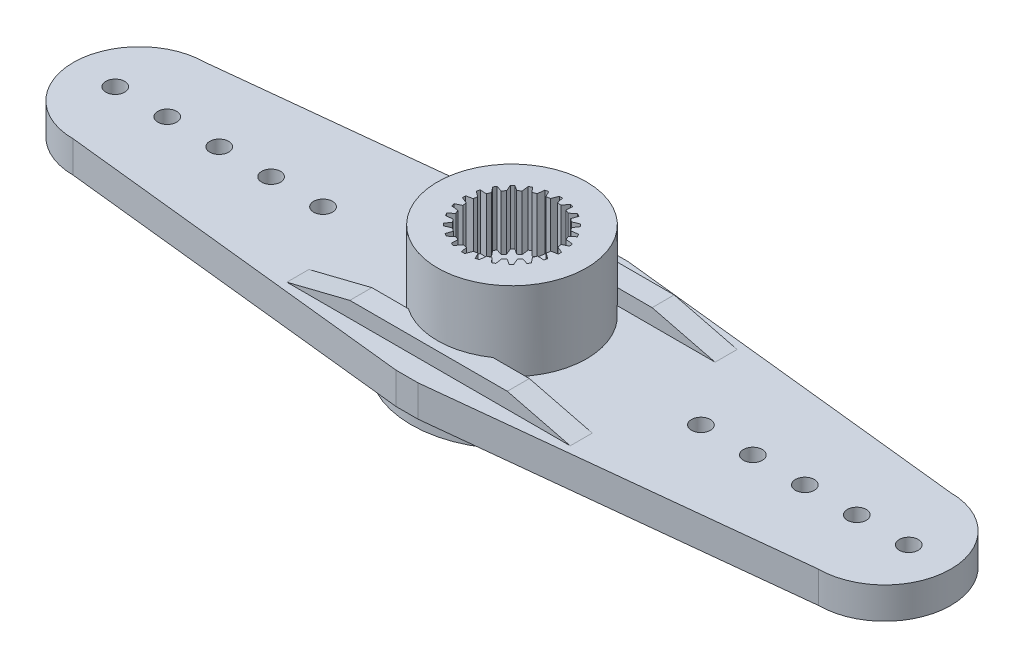
from build123d import *

# Parameters (mm, degrees)
IZIM1_R                     = 6.4
IZIM1_R_2                   = 4.735
Y_KSEKLIK_EKSTR_ZYON1_DEPTH = 2.8
IZIM3_R                     = 4.735
Y_KSEKLIK_EKSTR_ZYON3_DEPTH = 7.8
IZIM6_R                     = 0.6
Y_KSEKLIK_EKSTR_ZYON5_DEPTH = 2
Y_KSEKLIK_EKSTR_ZYON6_DEPTH = 0.8
KES_EKSTR_ZYON1_DEPTH       = 2
KES_EKSTR_ZYON2_DEPTH       = 2
KES_EKSTR_ZYON3_DEPTH       = 2
KES_EKSTR_ZYON4_DEPTH       = 2
KES_EKSTR_ZYON5_DEPTH       = 2
KES_EKSTR_ZYON6_DEPTH       = 2
IZIM16_R                    = 3.1
KES_EKSTR_ZYON8_DEPTH       = 3
IZIM18_W                    = 18
IZIM18_H                    = 1.4
Y_KSEKLIK_EKSTR_ZYON7_DEPTH = 1
KES_EKSTR_ZYON11_DEPTH      = 12
IZIM20_R                    = 2.68
KES_EKSTR_ZYON13_DEPTH      = 3.5
IZIM21_R                    = 1.65
KES_EKSTR_ZYON14_DEPTH      = 3.5
KES_EKSTR_ZYON16_DEPTH      = 12.5
DAIRESEL_KAPLAMA1_COUNT     = 24


with BuildPart() as part:
    # Çizim1 → Yükseklik-Ekstrüzyon1 (new body)
    with BuildSketch(Plane(origin=(0, 0, 0), x_dir=(1, 0, 0), z_dir=(0, 1, 0))):
        with Locations(Location((0, 0, 0), (0, 0, 270))):
            Circle(IZIM1_R)
        with Locations(Location((0, 0, 0), (0, 0, 270))):
            Circle(IZIM1_R_2, mode=Mode.SUBTRACT)
    extrude(amount=Y_KSEKLIK_EKSTR_ZYON1_DEPTH)

    # Çizim3 → Yükseklik-Ekstrüzyon3 (add)
    with BuildSketch(Plane.XZ):
        with Locations(Location((0, 0, 0), (0, 0, 270))):
            Circle(IZIM3_R)
    extrude(amount=-Y_KSEKLIK_EKSTR_ZYON3_DEPTH)

    # Çizim6 → Yükseklik-Ekstrüzyon5 (add)
    with BuildSketch(Plane(origin=(0, 0.8, 0), x_dir=(-1, 0, 0), z_dir=(0, -1, 0))):
        with BuildLine():
            Line((-0.7, 6.67), (0.7, 6.67))
            Line((0.7, 6.67), (23.67, 4.2))
            ThreePointArc((23.67, 4.2), (27.87, 0), (23.67, -4.2))
            Line((23.67, -4.2), (0.7, -6.67))
            Line((0.7, -6.67), (-0.7, -6.67))
            Line((-0.7, -6.67), (-23.67, -4.2))
            ThreePointArc((-23.67, -4.2), (-27.87, 0), (-23.67, 4.2))
            Line((-23.67, 4.2), (-0.7, 6.67))
        make_face()
        with Locations(Location((12, 0, 0), (0, 0, 90))):
            Circle(IZIM6_R, mode=Mode.SUBTRACT)
        with Locations(Location((18.6, 0, 0), (0, 0, 90))):
            Circle(IZIM6_R, mode=Mode.SUBTRACT)
        with Locations(Location((21.9, 0, 0), (0, 0, 90))):
            Circle(IZIM6_R, mode=Mode.SUBTRACT)
        with Locations(Location((25.2, 0, 0), (0, 0, 90))):
            Circle(IZIM6_R, mode=Mode.SUBTRACT)
        with Locations(Location((15.3, 0, 0), (0, 0, 90))):
            Circle(IZIM6_R, mode=Mode.SUBTRACT)
        with Locations(Location((-12, 0, 0), (0, 0, 270))):
            Circle(IZIM6_R, mode=Mode.SUBTRACT)
        with Locations(Location((-15.3, 0, 0), (0, 0, 270))):
            Circle(IZIM6_R, mode=Mode.SUBTRACT)
        with Locations(Location((-18.6, 0, 0), (0, 0, 270))):
            Circle(IZIM6_R, mode=Mode.SUBTRACT)
        with Locations(Location((-21.9, 0, 0), (0, 0, 270))):
            Circle(IZIM6_R, mode=Mode.SUBTRACT)
        with Locations(Location((-25.2, 0, 0), (0, 0, 270))):
            Circle(IZIM6_R, mode=Mode.SUBTRACT)
    extrude(amount=-Y_KSEKLIK_EKSTR_ZYON5_DEPTH)

    # Çizim7 → Yükseklik-Ekstrüzyon6 (add)
    with BuildSketch(Plane(origin=(0, 0.8, 0), x_dir=(-1, 0, 0), z_dir=(0, -1, 0))):
        with BuildLine():
            Line((-3.587478223, 5.3), (-9, 5.3))
            Line((-9, 5.3), (-9, 3.9))
            Line((-9, 3.9), (-5.074445783, 3.9))
            ThreePointArc((-5.074445783, 3.9), (-4.387166725, 4.659696141), (-3.587478223, 5.3))
        make_face()
        with BuildLine():
            ThreePointArc((-6.361553478, -0.700455101), (-6.399999984, -0.000457848), (-6.361653632, 0.699544899))
            Line((-6.361653632, 0.699544899), (-9, 0.699544899))
            Line((-9, 0.699544899), (-9, -0.700455101))
            Line((-9, -0.700455101), (-6.361553478, -0.700455101))
        make_face()
        with BuildLine():
            ThreePointArc((-3.587478223, -5.3), (-4.387166725, -4.659696141), (-5.074445783, -3.9))
            Line((-5.074445783, -3.9), (-9, -3.9))
            Line((-9, -3.9), (-9, -5.3))
            Line((-9, -5.3), (-3.587478223, -5.3))
        make_face()
        with BuildLine():
            Line((9, -3.9), (5.074445783, -3.9))
            ThreePointArc((5.074445783, -3.9), (4.387166725, -4.659696141), (3.587478223, -5.3))
            Line((3.587478223, -5.3), (9, -5.3))
            Line((9, -5.3), (9, -3.9))
        make_face()
        with BuildLine():
            Line((9, 0.699544899), (6.361653632, 0.699544899))
            ThreePointArc((6.361653632, 0.699544899), (6.390406217, 0.350297556), (6.4, 0))
            ThreePointArc((6.4, 0), (6.390381141, -0.350754716), (6.361553478, -0.700455101))
            Line((6.361553478, -0.700455101), (9, -0.700455101))
            Line((9, -0.700455101), (9, 0.699544899))
        make_face()
        with BuildLine():
            Line((9, 5.3), (3.587478223, 5.3))
            ThreePointArc((3.587478223, 5.3), (4.387166725, 4.659696141), (5.074445783, 3.9))
            Line((5.074445783, 3.9), (9, 3.9))
            Line((9, 3.9), (9, 5.3))
        make_face()
    extrude(amount=Y_KSEKLIK_EKSTR_ZYON6_DEPTH)

    # Çizim8 → Kes-Ekstrüzyon1 (cut)
    with BuildSketch(Plane.XY.offset(-3.9)):
        Polygon((-9, 0.8), (-9, 0), (-5.074445783, 0), align=None)
    extrude(amount=-KES_EKSTR_ZYON1_DEPTH, mode=Mode.SUBTRACT)

    # Çizim10 → Kes-Ekstrüzyon2 (cut)
    with BuildSketch(Plane.XY.offset(0.700455101)):
        Polygon((-6.361553478, 0), (-9, 0.8), (-9, 0), align=None)
    extrude(amount=-KES_EKSTR_ZYON2_DEPTH, mode=Mode.SUBTRACT)

    # Çizim11 → Kes-Ekstrüzyon3 (cut)
    with BuildSketch(Plane(origin=(0, 0, 3.9), x_dir=(-1, 0, 0), z_dir=(0, 0, -1))):
        Polygon((9, 0.8), (9, 0), (5.074445783, 0), align=None)
    extrude(amount=-KES_EKSTR_ZYON3_DEPTH, mode=Mode.SUBTRACT)

    # Çizim12 → Kes-Ekstrüzyon4 (cut)
    with BuildSketch(Plane(origin=(0, 0, 3.9), x_dir=(-1, 0, 0), z_dir=(0, 0, -1))):
        Polygon((-5.074445783, 0), (-9, 0.8), (-9, 0), align=None)
    extrude(amount=-KES_EKSTR_ZYON4_DEPTH, mode=Mode.SUBTRACT)

    # Çizim13 → Kes-Ekstrüzyon5 (cut)
    with BuildSketch(Plane.XY.offset(0.700455101)):
        Polygon((9, 0.8), (6.361553478, 0), (9, 0), align=None)
    extrude(amount=-KES_EKSTR_ZYON5_DEPTH, mode=Mode.SUBTRACT)

    # Çizim14 → Kes-Ekstrüzyon6 (cut)
    with BuildSketch(Plane.XY.offset(-3.9)):
        Polygon((9, 0), (9, 0.8), (5.074445783, 0), align=None)
    extrude(amount=-KES_EKSTR_ZYON6_DEPTH, mode=Mode.SUBTRACT)

    # Çizim16 → Kes-Ekstrüzyon8 (cut)
    with BuildSketch(Plane(origin=(0, 0, 0), x_dir=(-1, 0, 0), z_dir=(0, -1, 0))):
        with Locations(Location((0, 0, 0), (0, 0, 90))):
            Circle(IZIM16_R)
    extrude(amount=-KES_EKSTR_ZYON8_DEPTH, mode=Mode.SUBTRACT)

    # Çizim17 → Kes-Döndür1 (revolve, cut)
    with BuildSketch(Plane(origin=(0, 0, 0), x_dir=(-1, 0, 0), z_dir=(0, 0, -1)), mode=Mode.PRIVATE) as kes_d_nd_r1_sk:
        Polygon((0, 0), (0, 1.8), (-3.1, 1.8), (-3.9, 1), (-3.9, 0), align=None)
    revolve(kes_d_nd_r1_sk.sketch.rotate(Axis((0, 0, 0), (0, 1, 0)), 90), axis=Axis((0, 0, 0), (0, 1, 0)), mode=Mode.SUBTRACT)

    # Çizim18 → Yükseklik-Ekstrüzyon7 (add)
    with BuildSketch(Plane(origin=(0, 2.8, 0), x_dir=(1, 0, 0), z_dir=(0, 1, 0))):
        with Locations((0, 4.6)):
            Rectangle(IZIM18_W, IZIM18_H)
        with Locations((0, -4.6)):
            Rectangle(IZIM18_W, IZIM18_H)
    extrude(amount=Y_KSEKLIK_EKSTR_ZYON7_DEPTH)

    # Çizim19 → Kes-Ekstrüzyon11 (cut)
    with BuildSketch(Plane.XY.offset(5.3)):
        Polygon((-5, 3.8), (-9, 3.8), (-9, 2.8), align=None)
        Polygon((5, 3.8), (9, 3.8), (9, 2.8), align=None)
    extrude(amount=-KES_EKSTR_ZYON11_DEPTH, mode=Mode.SUBTRACT)

    # Çizim20 → Kes-Ekstrüzyon13 (cut)
    with BuildSketch(Plane(origin=(0, 7.8, 0), x_dir=(1, 0, 0), z_dir=(0, 1, 0))):
        with Locations(Location((0, 0, 0), (0, 0, 270))):
            Circle(IZIM20_R)
    extrude(amount=-KES_EKSTR_ZYON13_DEPTH, mode=Mode.SUBTRACT)

    # Çizim21 → Kes-Ekstrüzyon14 (cut)
    with BuildSketch(Plane.XZ.offset(-3)):
        with Locations(Location((0, 0, 0), (0, 0, 270))):
            Circle(IZIM21_R)
    extrude(amount=-KES_EKSTR_ZYON14_DEPTH, mode=Mode.SUBTRACT)

    # Çizim22 → Kes-Ekstrüzyon16 (cut)
    with BuildSketch(Plane(origin=(0, 4.3, 0), x_dir=(1, 0, 0), z_dir=(0, 1, 0))):
        with BuildLine():
            Line((-2.934579919, 0.923625537), (-2.525449073, 0.896943132))
            ThreePointArc((-2.525449073, 0.896943132), (-2.59201793, 0.681060238), (-2.640168377, 0.460337854))
            Line((-2.640168377, 0.460337854), (-2.989922107, 0.724713202))
            ThreePointArc((-2.989922107, 0.724713202), (-2.963920139, 0.82463376), (-2.934579919, 0.923625537))
        make_face()
    kes_ekstr_zyon16 = extrude(amount=KES_EKSTR_ZYON16_DEPTH, mode=Mode.SUBTRACT)

    # Dairesel Kaplama1: Kes-Ekstrüzyon16 ×24 about axis
    dairesel_kaplama1_axis = Axis((0, 0, 0), (0, 1, 0))
    for i in range(1, DAIRESEL_KAPLAMA1_COUNT):
        add(kes_ekstr_zyon16.rotate(dairesel_kaplama1_axis, i * 360 / DAIRESEL_KAPLAMA1_COUNT), mode=Mode.SUBTRACT)


solid = part.part
